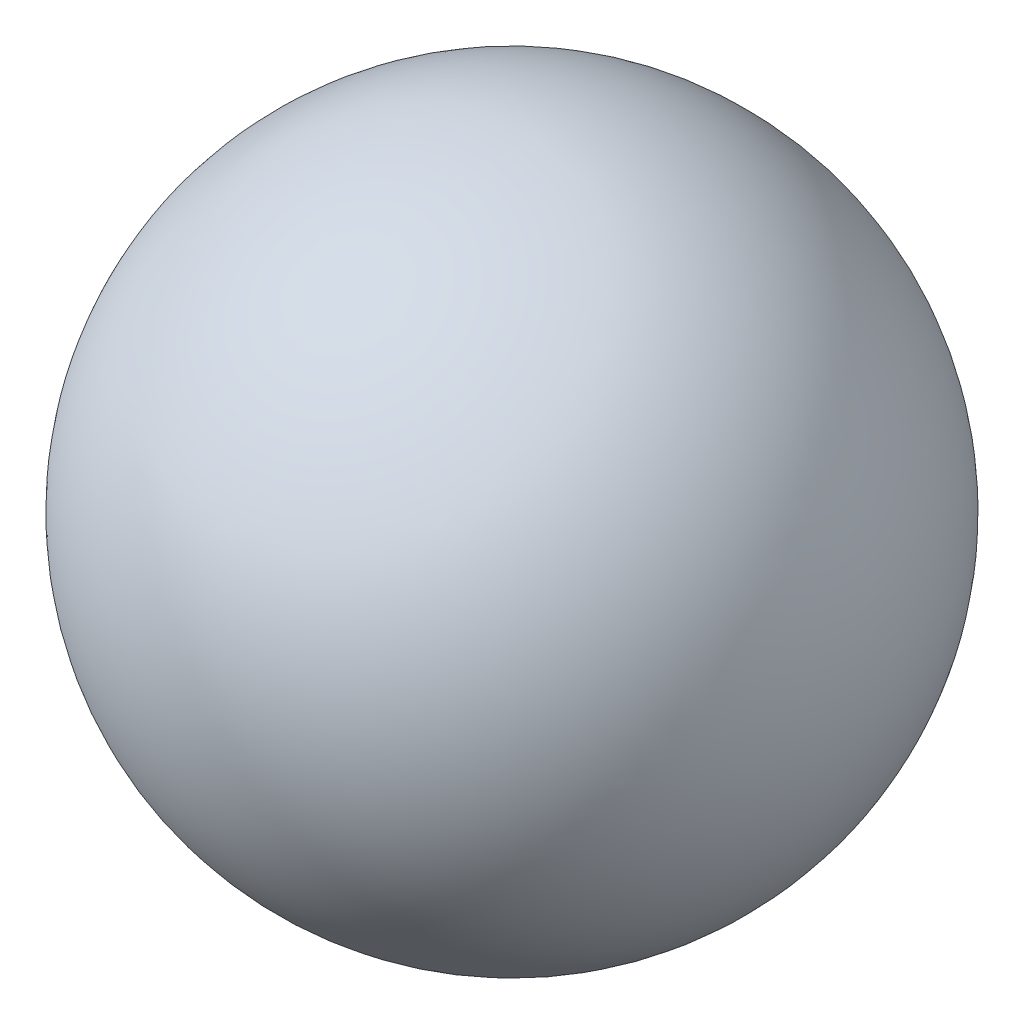
from build123d import *


with BuildPart() as part:
    # Sketch1 → Revolve1 (revolve)
    with BuildSketch(Plane.XY):
        with BuildLine():
            Line((1.05, 0), (-1.05, 0))
            ThreePointArc((-1.05, 0), (0, 1.05), (1.05, 0))
        make_face()
    revolve(axis=Axis((1.05, 0, 0), (-1, 0, 0)))


solid = part.part
